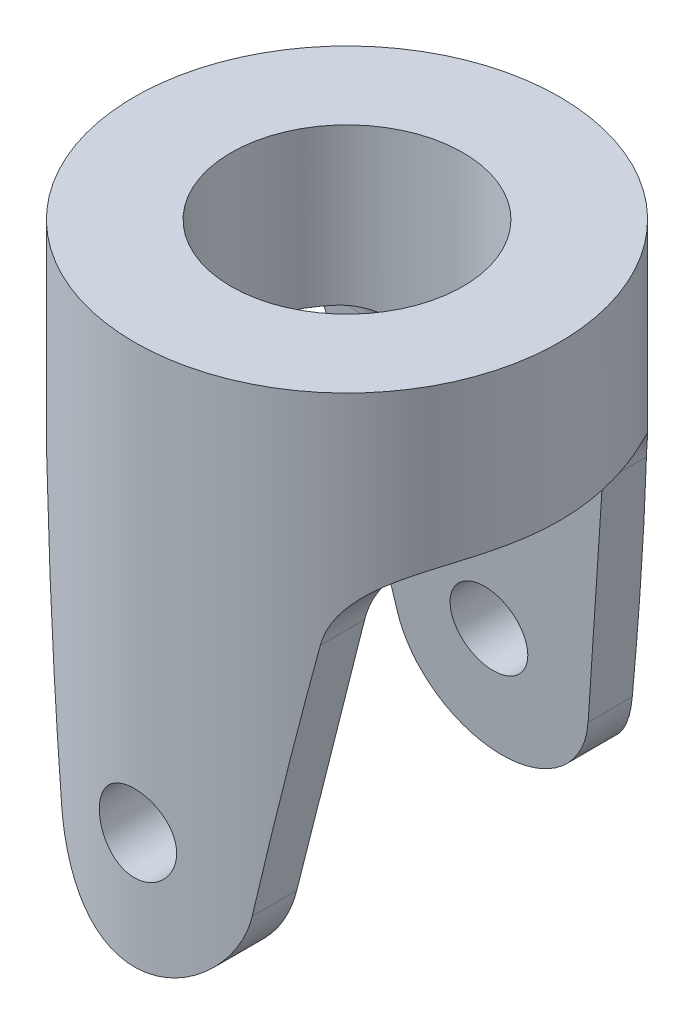
from build123d import *

# Parameters (mm, degrees)
SKETCH1_R               = 5.5
BOSS_EXTRUDE1_DEPTH     = 14
CUT_EXTRUDE3_DEPTH      = 6.5
CUT_EXTRUDE3_DEPTH_BACK = 6.5
CUT_EXTRUDE4_DEPTH      = 6.5000001
CUT_EXTRUDE4_DEPTH_BACK = 6.5000001
SKETCH5_R               = 3
CUT_EXTRUDE7_DEPTH      = 15.0000001
CUT_EXTRUDE7_DEPTH_BACK = 14
SKETCH6_R               = 1
CUT_EXTRUDE8_DEPTH      = 6.5000001
CUT_EXTRUDE8_DEPTH_BACK = 6.5000001


with BuildPart() as part:
    # Sketch1 → Boss-Extrude1 (new body)
    with BuildSketch(Plane(origin=(0, 0, 0), x_dir=(1, 0, 0), z_dir=(0, 1, 0))):
        Circle(SKETCH1_R)
    extrude(amount=BOSS_EXTRUDE1_DEPTH)

    # Sketch3 → Cut-Extrude3 (cut, two sides)
    with BuildSketch(Plane.XY) as cut_extrude3_sk:
        with BuildLine():
            Line((45.232137495, 10), (5.5, 10))
            ThreePointArc((5.5, 10), (4.209777241, 9.528177094), (3.528311133, 8.335325231))
            Line((3.528311133, 8.335325231), (2.464611084, 2.080843461))
            ThreePointArc((2.464611084, 2.080843461), (0, 0), (-2.464611084, 2.080843461))
            Line((-2.464611084, 2.080843461), (-3.528311133, 8.335325231))
            ThreePointArc((-3.528311133, 8.335325231), (-4.209777241, 9.528177094), (-5.5, 10))
            Line((-5.5, 10), (-45.232137495, 10))
            Line((-45.232137495, 10), (-45.232137495, -69.464274989))
            Line((-45.232137495, -69.464274989), (45.232137495, -69.464274989))
            Line((45.232137495, -69.464274989), (45.232137495, 10))
        make_face()
    extrude(amount=CUT_EXTRUDE3_DEPTH, mode=Mode.SUBTRACT)
    extrude(cut_extrude3_sk.sketch, amount=-CUT_EXTRUDE3_DEPTH_BACK, mode=Mode.SUBTRACT)

    # Sketch4 → Cut-Extrude4 (cut, two sides)
    with BuildSketch(Plane(origin=(0, 0, 0), x_dir=(0, 0, -1), z_dir=(1, 0, 0))) as cut_extrude4_sk:
        with BuildLine():
            Line((4.004785901, 0), (-3.995214099, 0))
            Line((-3.995214099, 0), (-2.98912449, 9.074785729))
            ThreePointArc((-2.98912449, 9.074785729), (-2.662225586, 9.709641809), (-1.995214099, 9.964594376))
            Line((-1.995214099, 9.964594376), (2.004785901, 9.964594376))
            ThreePointArc((2.004785901, 9.964594376), (2.671797388, 9.709641809), (2.998696292, 9.074785729))
            Line((2.998696292, 9.074785729), (4.004785901, 0))
        make_face()
    extrude(amount=CUT_EXTRUDE4_DEPTH, mode=Mode.SUBTRACT)
    extrude(cut_extrude4_sk.sketch, amount=-CUT_EXTRUDE4_DEPTH_BACK, mode=Mode.SUBTRACT)

    # Sketch5 → Cut-Extrude7 (cut, two sides)
    with BuildSketch(Plane(origin=(0, 0, 0), x_dir=(1, 0, 0), z_dir=(0, 1, 0))) as cut_extrude7_sk:
        Circle(SKETCH5_R)
    extrude(amount=CUT_EXTRUDE7_DEPTH, mode=Mode.SUBTRACT)
    extrude(cut_extrude7_sk.sketch, amount=-CUT_EXTRUDE7_DEPTH_BACK, mode=Mode.SUBTRACT)

    # Sketch6 → Cut-Extrude8 (cut, two sides)
    with BuildSketch(Plane.XY) as cut_extrude8_sk:
        with Locations((0, 3)):
            Circle(SKETCH6_R)
    extrude(amount=CUT_EXTRUDE8_DEPTH, mode=Mode.SUBTRACT)
    extrude(cut_extrude8_sk.sketch, amount=-CUT_EXTRUDE8_DEPTH_BACK, mode=Mode.SUBTRACT)


solid = part.part
